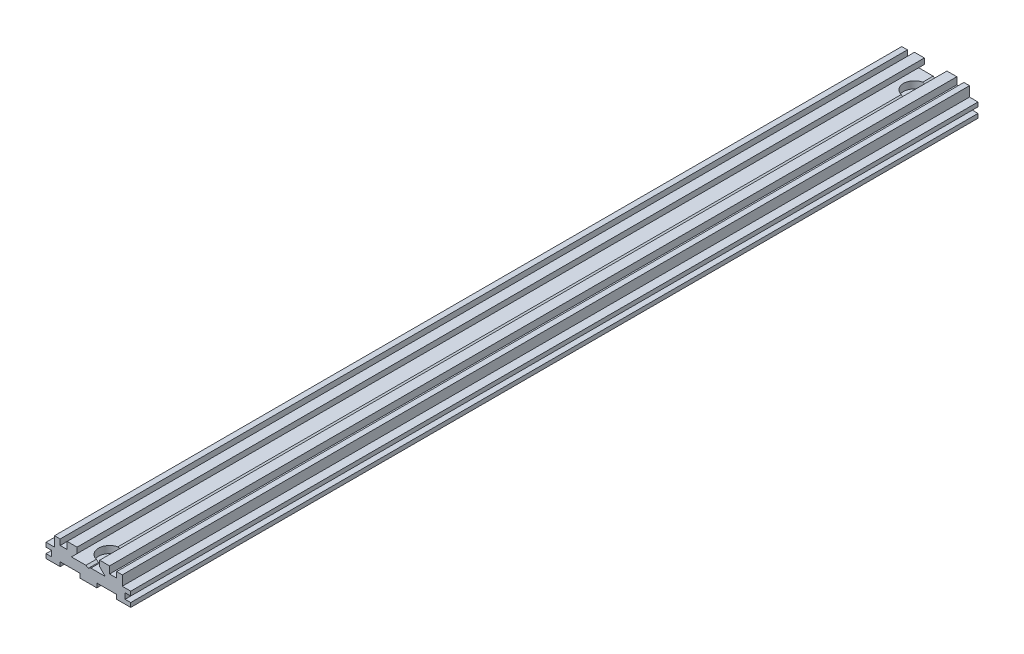
from build123d import *

# Parameters (mm, degrees)
EXTRUDE_1_DEPTH     = 150
CUT_EXTRUDE_2_REACH = 302
SKETCH_3_W          = 7
SKETCH_3_H          = 1.5
CUT_EXTRUDE_START   = -5
SKETCH_4_R          = 2.25
CUT_EXTRUDE_3_DEPTH = 5
SKETCH_5_R          = 3.9
CUT_EXTRUDE_4_DEPTH = 2.5


with BuildPart() as part:
    # 草图1 → 凸台-拉伸1 (new body, symmetric)
    with BuildSketch(Plane.XY):
        Polygon((7.5, 9), (7.5, 6.5), (5, 6.5), (5, 8.5), (3, 8.5), (3, 5), (0, 5), (0, 3.5), (2, 3.5), (2, 1.5), (0, 1.5), (0, 0), (30, 0), (30, 1.5), (28, 1.5), (28, 3.5), (30, 3.5), (30, 5), (27, 5), (27, 8.5), (25, 8.5), (25, 6.5), (22.5, 6.5), (22.5, 9), (19, 9), (19, 7), (21, 5), (9, 5), (11, 7), (11, 9), align=None)
    extrude(amount=EXTRUDE_1_DEPTH, both=True)

    # 草图3 → 切除-拉伸2 (cut, up to next)
    with BuildSketch(Plane.XY.offset(150), mode=Mode.PRIVATE) as cut_extrude_2_sk1:
        with Locations((8.5, 0.75)):
            Rectangle(SKETCH_3_W, SKETCH_3_H)
    cut_extrude_2_tool1 = extrude(cut_extrude_2_sk1.sketch, amount=-CUT_EXTRUDE_2_REACH, mode=Mode.PRIVATE) & part.part
    add(cut_extrude_2_tool1.solids().sort_by_distance((8.5, 0.75, 150))[0], mode=Mode.SUBTRACT)
    # 草图3 → 切除-拉伸2 (cut, up to next)
    with BuildSketch(Plane.XY.offset(150), mode=Mode.PRIVATE) as cut_extrude_2_sk2:
        with Locations((21.5, 0.75)):
            Rectangle(SKETCH_3_W, SKETCH_3_H)
    cut_extrude_2_tool2 = extrude(cut_extrude_2_sk2.sketch, amount=-CUT_EXTRUDE_2_REACH, mode=Mode.PRIVATE) & part.part
    add(cut_extrude_2_tool2.solids().sort_by_distance((21.5, 0.75, 150))[0], mode=Mode.SUBTRACT)
    # 草图3 → 切除-拉伸2 (cut, up to next)
    with BuildSketch(Plane.XY.offset(150), mode=Mode.PRIVATE) as cut_extrude_2_sk3:
        Polygon((14.133974596, 5), (15.866025404, 5), (15, 4.5), align=None)
    cut_extrude_2_tool3 = extrude(cut_extrude_2_sk3.sketch, amount=-CUT_EXTRUDE_2_REACH, mode=Mode.PRIVATE) & part.part
    add(cut_extrude_2_tool3.solids().sort_by_distance((15, 4.833333, 150))[0], mode=Mode.SUBTRACT)

    # 草图4 → 切除-拉伸3 (cut)
    with BuildSketch(Plane(origin=(0, 5, 0), x_dir=(1, 0, 0), z_dir=(0, 1, 0)).offset(CUT_EXTRUDE_START)):
        with Locations(Location((15, 142.5, 0), (0, 0, 90))):  # turned: the seam where the file's is
            Circle(SKETCH_4_R)
    cut_extrude_3 = extrude(amount=CUT_EXTRUDE_3_DEPTH, mode=Mode.SUBTRACT)

    # 草图5 → 切除-拉伸4 (cut)
    with BuildSketch(Plane(origin=(0, 5, 0), x_dir=(1, 0, 0), z_dir=(0, 1, 0))):
        with Locations(Location((15, 142.5, 0), (0, 0, 270))):  # turned: the seam where the file's is
            Circle(SKETCH_5_R)
    cut_extrude_4 = extrude(amount=-CUT_EXTRUDE_4_DEPTH, mode=Mode.SUBTRACT)

    # 镜向1: 切除-拉伸3, 切除-拉伸4 across plane
    add(cut_extrude_3.mirror(Plane.XY), mode=Mode.SUBTRACT)
    add(cut_extrude_4.mirror(Plane.XY), mode=Mode.SUBTRACT)


solid = part.part
